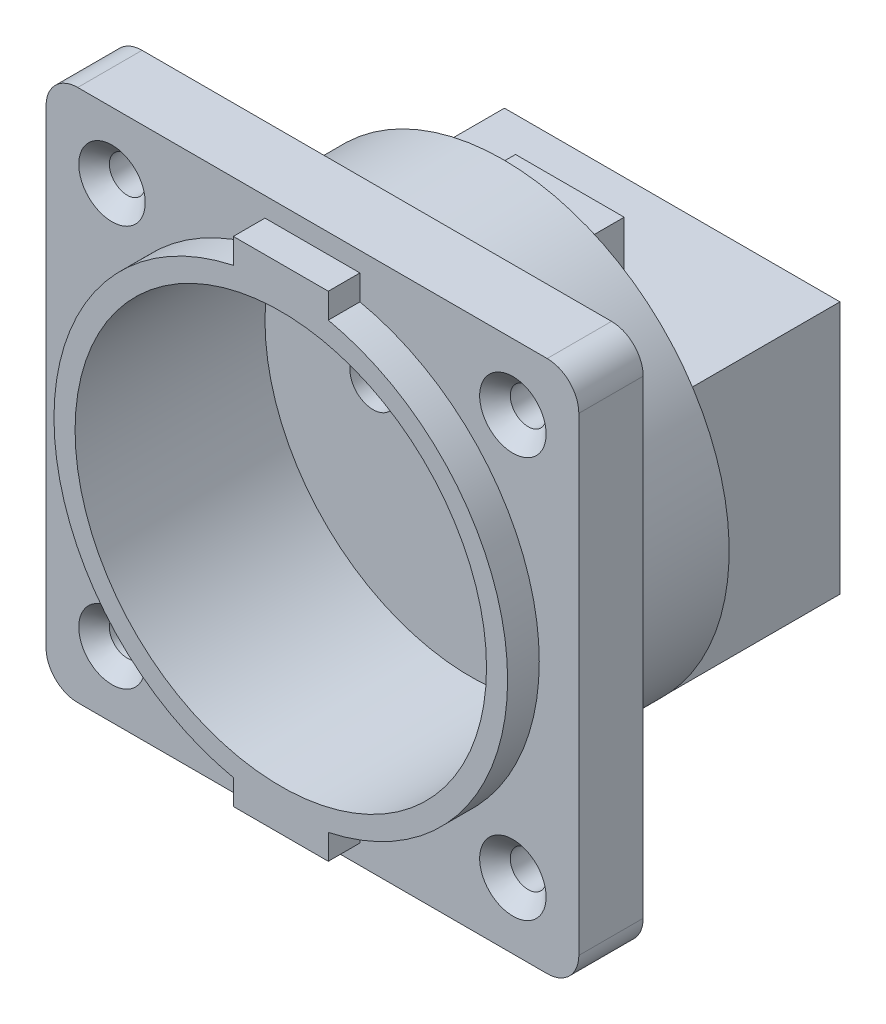
from build123d import *

# Parameters (mm, degrees)
SKIZZE1_W                                            = 50.5
SKIZZE1_H                                            = 50.5
AUFSATZ_LINEAR_AUSTRAGEN1_DEPTH                      = 6.1
AUFSATZ_LINEAR_AUSTRAGEN2_DEPTH                      = 3
SKIZZE3_R                                            = 21.4
AUFSATZ_LINEAR_AUSTRAGEN3_DEPTH                      = 12
SKIZZE4_W                                            = 31.8
SKIZZE4_H                                            = 24
AUFSATZ_LINEAR_AUSTRAGEN4_DEPTH                      = 16
FORMSENKUNG_F_R_M3_LINSENSENKSCHRAUBE_MI_D           = 3.4
FORMSENKUNG_F_R_M3_LINSENSENKSCHRAUBE_MI_CSINK_D     = 6.3
FORMSENKUNG_F_R_M3_LINSENSENKSCHRAUBE_MI_CSINK_ANGLE = 90
VERRUNDUNG1_R                                        = 3
SKIZZE7_R                                            = 19.5
SCHNITT_LINEAR_AUSTRAGEN1_DEPTH                      = 18
F_4_4_4_4_DURCHMESSER_BOHRUNG1_D                     = 4.4
SKIZZE10_W                                           = 10.3
SKIZZE10_H                                           = 6.423058333
AUFSATZ_LINEAR_AUSTRAGEN5_DEPTH                      = 6.3


with BuildPart() as part:
    # Skizze1 → Aufsatz-Linear austragen1 (new body)
    with BuildSketch(Plane.XY):
        Rectangle(SKIZZE1_W, SKIZZE1_H)
    extrude(amount=AUFSATZ_LINEAR_AUSTRAGEN1_DEPTH)

    # Skizze2 → Aufsatz-Linear austragen2 (add)
    with BuildSketch(Plane.XY.offset(6.1)):
        with BuildLine():
            Line((-4.5, -21.023796042), (-4.5, 21.023796042))
            ThreePointArc((-4.5, 21.023796042), (-21.5, 0), (-4.5, -21.023796042))
        make_face()
        with BuildLine():
            ThreePointArc((4.5, 21.023796042), (0, 21.5), (-4.5, 21.023796042))
            Line((-4.5, 21.023796042), (-4.5, -21.023796042))
            ThreePointArc((-4.5, -21.023796042), (0, -21.5), (4.5, -21.023796042))
            Line((4.5, -21.023796042), (4.5, 21.023796042))
        make_face()
        with BuildLine():
            ThreePointArc((21.5, 0), (16.718253497, 13.518505835), (4.5, 21.023796042))
            Line((4.5, 21.023796042), (4.5, -21.023796042))
            ThreePointArc((4.5, -21.023796042), (16.718253497, -13.518505835), (21.5, 0))
        make_face()
        with BuildLine():
            Line((4.5, 23.4), (-4.5, 23.4))
            Line((-4.5, 23.4), (-4.5, 21.023796042))
            ThreePointArc((-4.5, 21.023796042), (0, 21.5), (4.5, 21.023796042))
            Line((4.5, 21.023796042), (4.5, 23.4))
        make_face()
        with BuildLine():
            ThreePointArc((4.5, -21.023796042), (0, -21.5), (-4.5, -21.023796042))
            Line((-4.5, -21.023796042), (-4.5, -23.4))
            Line((-4.5, -23.4), (4.5, -23.4))
            Line((4.5, -23.4), (4.5, -21.023796042))
        make_face()
    extrude(amount=AUFSATZ_LINEAR_AUSTRAGEN2_DEPTH)

    # Skizze3 → Aufsatz-Linear austragen3 (add)
    with BuildSketch(Plane(origin=(0, 0, 0), x_dir=(-1, 0, 0), z_dir=(0, 0, -1))):
        Circle(SKIZZE3_R)
    extrude(amount=AUFSATZ_LINEAR_AUSTRAGEN3_DEPTH)

    # Skizze4 → Aufsatz-Linear austragen4 (add)
    with BuildSketch(Plane(origin=(0, 0, -12), x_dir=(-1, 0, 0), z_dir=(0, 0, -1))):
        with Locations((0, -2.323058333)):
            Rectangle(SKIZZE4_W, SKIZZE4_H)
    extrude(amount=AUFSATZ_LINEAR_AUSTRAGEN4_DEPTH)

    # Formsenkung für M3 Linsensenkschraube mit Schlitz1 (through all)
    with Locations(Plane.XY.offset(6.1)):
        with Locations((-19, 19), (19, 19), (19, -19), (-19, -19)):
            CounterSinkHole(FORMSENKUNG_F_R_M3_LINSENSENKSCHRAUBE_MI_D / 2, FORMSENKUNG_F_R_M3_LINSENSENKSCHRAUBE_MI_CSINK_D / 2, counter_sink_angle=FORMSENKUNG_F_R_M3_LINSENSENKSCHRAUBE_MI_CSINK_ANGLE)

    # Verrundung1
    verrundung1_edges = [part.edges().sort_by_distance(p)[0] for p in [
        (25.25, -25.25, 3.05),
        (-25.25, -25.25, 3.05),
        (-25.25, 25.25, 3.05),
        (25.25, 25.25, 3.05),
    ]]
    fillet(verrundung1_edges, radius=VERRUNDUNG1_R)

    # Skizze7 → Schnitt-Linear austragen1 (cut)
    with BuildSketch(Plane.XY.offset(9.1)):
        Circle(SKIZZE7_R)
    extrude(amount=-SCHNITT_LINEAR_AUSTRAGEN1_DEPTH, mode=Mode.SUBTRACT)

    # Ø4.4 (4.4) Durchmesser Bohrung1 (through all)
    with Locations(Plane.XY.offset(-8.9)):
        with Locations((-9.25, 0), (9.25, 0)):
            Hole(F_4_4_4_4_DURCHMESSER_BOHRUNG1_D / 2)

    # Skizze10 → Aufsatz-Linear austragen5 (add)
    with BuildSketch(Plane(origin=(0, 0, -12), x_dir=(-1, 0, 0), z_dir=(0, 0, -1))):
        with Locations((0, 12.888470834)):
            Rectangle(SKIZZE10_W, SKIZZE10_H)
    extrude(amount=AUFSATZ_LINEAR_AUSTRAGEN5_DEPTH)


solid = part.part
